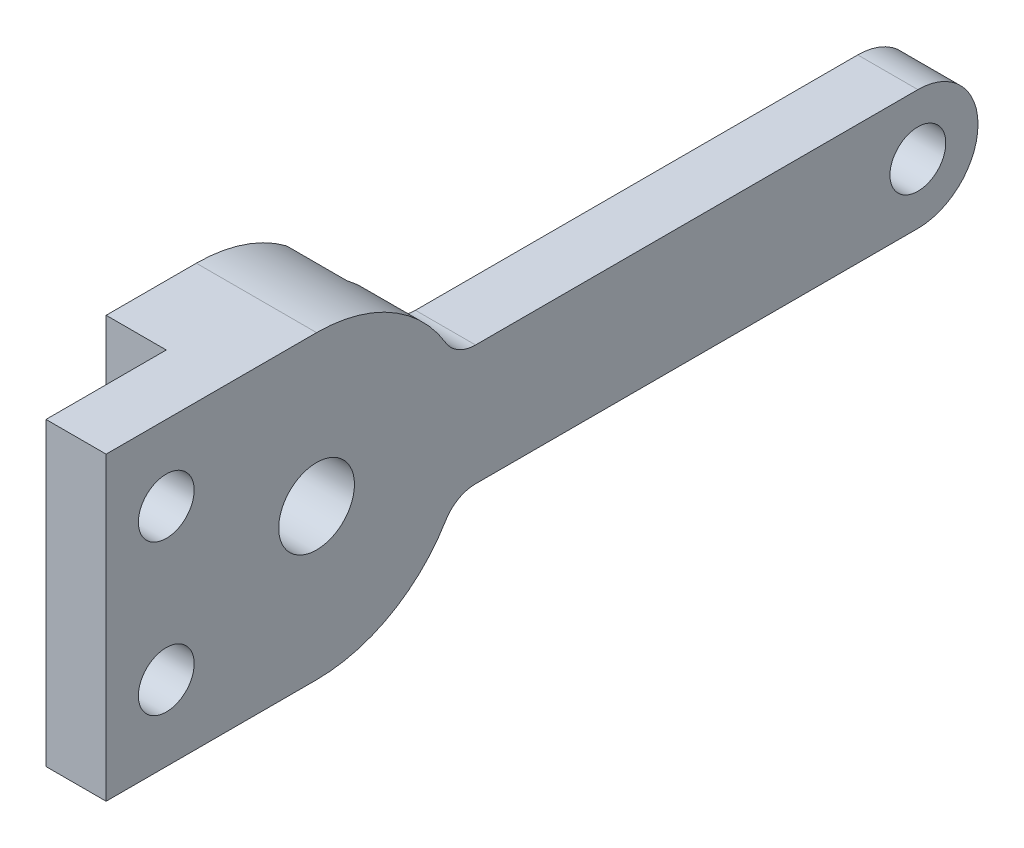
from build123d import *

# Parameters (mm, degrees)
SKETCH1_R             = 2
BOSS_EXTRUDE1_DEPTH   = 6.35
FILLET1_R             = 1.8415
SKETCH2_W             = 6.35
SKETCH2_H             = 15.875
SKETCH2_W_2           = 42.387227331
SKETCH2_H_2           = 26.263521184
CUT_EXTRUDE1_DEPTH    = 3.175
F_4_CLEARANCE_HOLE1_D = 2.9464
F_4_CLEARANCE_HOLE2_D = 2.9464


with BuildPart() as part:
    # Sketch1 → Boss-Extrude1 (new body)
    with BuildSketch(Plane(origin=(0, 0, 0), x_dir=(0, 0, -1), z_dir=(1, 0, 0))):
        with BuildLine():
            Line((-11.1125, 7.9375), (0, 7.9375))
            ThreePointArc((0, 7.9375), (4.3475478, 6.640988961), (7.274838916, 3.175))
            Line((7.274838916, 3.175), (31.75, 3.175))
            ThreePointArc((31.75, 3.175), (34.925, 0), (31.75, -3.175))
            Line((31.75, -3.175), (7.274838916, -3.175))
            ThreePointArc((7.274838916, -3.175), (4.3475478, -6.640988961), (0, -7.9375))
            Line((0, -7.9375), (-11.1125, -7.9375))
            Line((-11.1125, -7.9375), (-11.1125, 7.9375))
        make_face()
        Circle(SKETCH1_R, mode=Mode.SUBTRACT)
    extrude(amount=BOSS_EXTRUDE1_DEPTH)

    # Fillet1
    fillet1_edges = [part.edges().sort_by_distance(p)[0] for p in [
        (3.175, 3.175, -7.274838916),
        (3.175, -3.175, -7.274838916),
    ]]
    fillet(fillet1_edges, radius=FILLET1_R)

    # Sketch2 → Cut-Extrude1 (cut)
    with BuildSketch(Plane.ZY):
        with Locations((7.9375, 0)):
            Rectangle(SKETCH2_W, SKETCH2_H)
        with Locations((-25.956113666, -1.270701279)):
            Rectangle(SKETCH2_W_2, SKETCH2_H_2)
    extrude(amount=-CUT_EXTRUDE1_DEPTH, mode=Mode.SUBTRACT)

    # #4 Clearance Hole1 (through all)
    with Locations(Plane(origin=(6.35, 0, 0), x_dir=(0, 0, -1), z_dir=(1, 0, 0))):
        with Locations((-7.9375, 3.96875), (-7.9375, -3.96875)):
            Hole(F_4_CLEARANCE_HOLE1_D / 2)

    # #4 Clearance Hole2 (through all)
    with Locations(Plane.ZY.offset(-3.175)):
        with Locations((-31.75, 0)):
            Hole(F_4_CLEARANCE_HOLE2_D / 2)


solid = part.part
